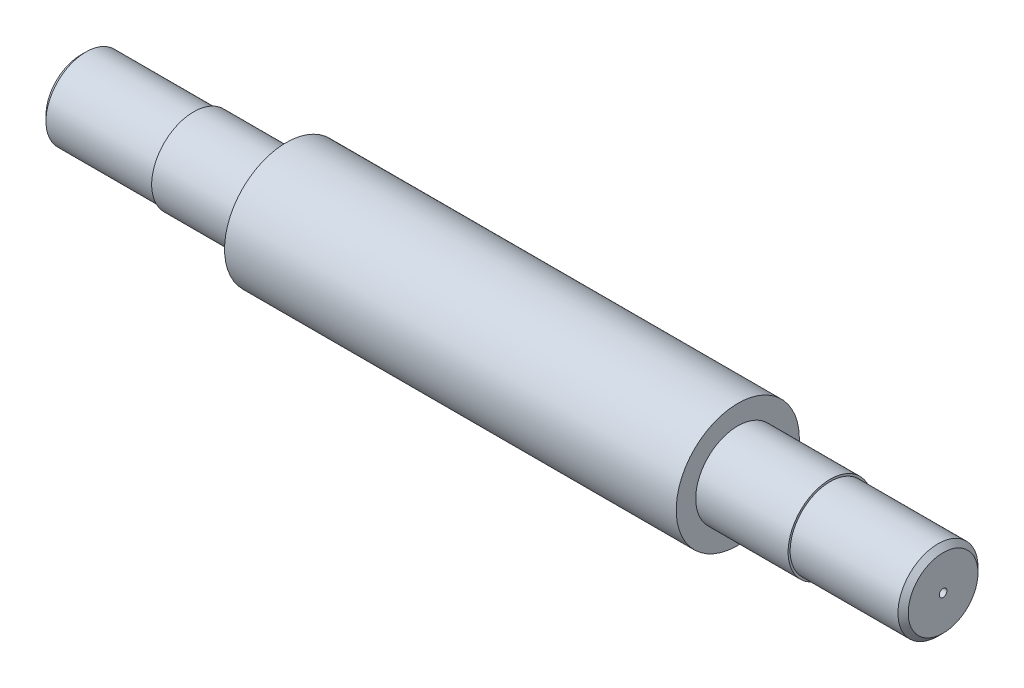
from build123d import *

# Parameters (mm, degrees)
SKETCH1_R           = 60
BOSS_EXTRUDE1_DEPTH = 220
SKETCH2_R           = 41
BOSS_EXTRUDE2_DEPTH = 310
SKETCH3_R           = 39
BOSS_EXTRUDE3_DEPTH = 420
SKETCH4_R           = 3.75
CUT_EXTRUDE1_DEPTH  = 6.25
SKETCH5_R           = 3.6
CUT_EXTRUDE2_DEPTH  = 6.25
CHAMFER1_SIZE       = 5


with BuildPart() as part:
    # Sketch1 → Boss-Extrude1 (new body, symmetric)
    with BuildSketch(Plane(origin=(0, 0, 0), x_dir=(0, 0, -1), z_dir=(1, 0, 0))):
        Circle(SKETCH1_R)
    extrude(amount=BOSS_EXTRUDE1_DEPTH, both=True)

    # Sketch2 → Boss-Extrude2 (add, symmetric)
    with BuildSketch(Plane(origin=(0, 0, 0), x_dir=(0, 0, -1), z_dir=(1, 0, 0))):
        Circle(SKETCH2_R)
    extrude(amount=BOSS_EXTRUDE2_DEPTH, both=True)

    # Sketch3 → Boss-Extrude3 (add, symmetric)
    with BuildSketch(Plane(origin=(0, 0, 0), x_dir=(0, 0, -1), z_dir=(1, 0, 0))):
        Circle(SKETCH3_R)
    extrude(amount=BOSS_EXTRUDE3_DEPTH, both=True)

    # Sketch4 → Cut-Extrude1 (cut)
    with BuildSketch(Plane(origin=(420, 0, 0), x_dir=(0, 0, -1), z_dir=(1, 0, 0))):
        Circle(SKETCH4_R)
    extrude(amount=-CUT_EXTRUDE1_DEPTH, mode=Mode.SUBTRACT)

    # Sketch5 → Cut-Extrude2 (cut)
    with BuildSketch(Plane.ZY.offset(420)):
        Circle(SKETCH5_R)
    extrude(amount=-CUT_EXTRUDE2_DEPTH, mode=Mode.SUBTRACT)

    # Chamfer1
    chamfer1_edges = [part.edges().sort_by_distance(p)[0] for p in [
        (-420, 0, 39),
        (420, 0, 39),
    ]]
    chamfer(chamfer1_edges, length=CHAMFER1_SIZE)


solid = part.part
